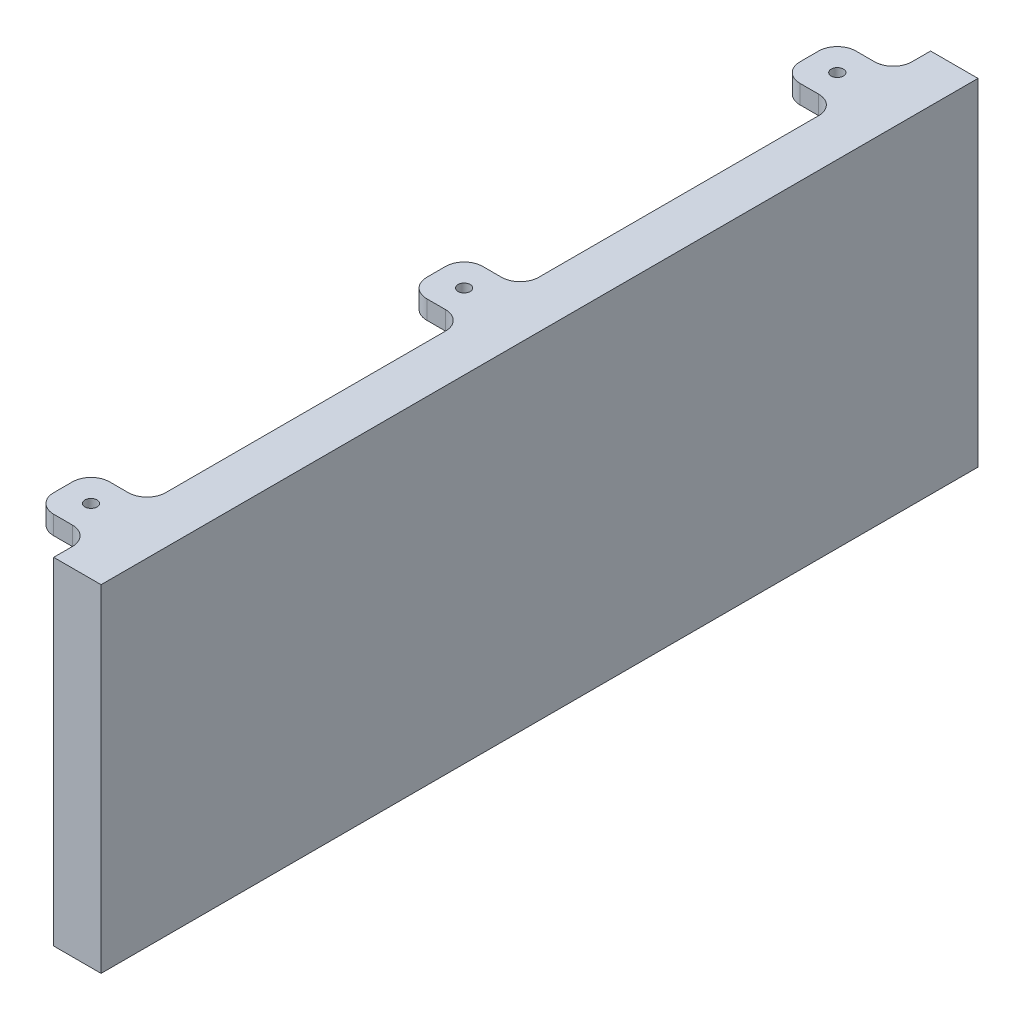
from build123d import *

# Parameters (mm, degrees)
SKETCH1_W                                      = 12.7
SKETCH1_H                                      = 234.95
BOSS_EXTRUDE1_DEPTH                            = 90.2
SKETCH3_W                                      = 15
SKETCH3_H                                      = 15
BOSS_EXTRUDE2_DEPTH                            = 5
CSK_FOR_4_FLAT_HEAD_MACHINE_SCREW1_D           = 3.2639
CSK_FOR_4_FLAT_HEAD_MACHINE_SCREW1_DEPTH       = 5
CSK_FOR_4_FLAT_HEAD_MACHINE_SCREW1_CSINK_D     = 5.715
CSK_FOR_4_FLAT_HEAD_MACHINE_SCREW1_CSINK_ANGLE = 82
FILLET1_R                                      = 5
FILLET2_R                                      = 3


with BuildPart() as part:
    # Sketch1 → Boss-Extrude1 (new body)
    with BuildSketch(Plane(origin=(0, 0, 0), x_dir=(1, 0, 0), z_dir=(0, 1, 0))):
        Rectangle(SKETCH1_W, SKETCH1_H)
    extrude(amount=BOSS_EXTRUDE1_DEPTH)

    # Sketch3 → Boss-Extrude2 (add)
    with BuildSketch(Plane(origin=(0, 90.2, 0), x_dir=(1, 0, 0), z_dir=(0, 1, 0))):
        with Locations((-13.85, 99.975)):
            Rectangle(SKETCH3_W, SKETCH3_H)
        with Locations((-13.85, -99.975)):
            Rectangle(SKETCH3_W, SKETCH3_H)
        with Locations((-13.85, 0)):
            Rectangle(SKETCH3_W, SKETCH3_H)
    extrude(amount=-BOSS_EXTRUDE2_DEPTH)

    # CSK for #4 Flat Head Machine Screw1
    with Locations(Plane.XZ.offset(-85.2)):
        with Locations((-13.85, 99.975), (-13.85, 0), (-13.85, -99.975)):
            CounterSinkHole(CSK_FOR_4_FLAT_HEAD_MACHINE_SCREW1_D / 2, CSK_FOR_4_FLAT_HEAD_MACHINE_SCREW1_CSINK_D / 2, depth=CSK_FOR_4_FLAT_HEAD_MACHINE_SCREW1_DEPTH, counter_sink_angle=CSK_FOR_4_FLAT_HEAD_MACHINE_SCREW1_CSINK_ANGLE)

    # Fillet1
    fillet1_edges = [part.edges().sort_by_distance(p)[0] for p in [
        (-6.35, 87.7, -107.475),
        (-6.35, 87.7, -92.475),
        (-21.35, 87.7, -92.475),
        (-21.35, 87.7, -107.475),
        (-6.35, 87.7, 92.475),
        (-6.35, 87.7, 107.475),
        (-21.35, 87.7, 107.475),
        (-21.35, 87.7, 92.475),
        (-21.35, 87.7, 7.5),
        (-21.35, 87.7, -7.5),
        (-6.35, 87.7, -7.5),
        (-6.35, 87.7, 7.5),
    ]]
    fillet(fillet1_edges, radius=FILLET1_R)

    # Fillet2
    fillet2_edges = [part.edges().sort_by_distance(p)[0] for p in [
        (-6.35, 85.2, -99.975),
        (-6.35, 85.2, 99.975),
        (-6.35, 85.2, 0),
    ]]
    fillet(fillet2_edges, radius=FILLET2_R)


solid = part.part
